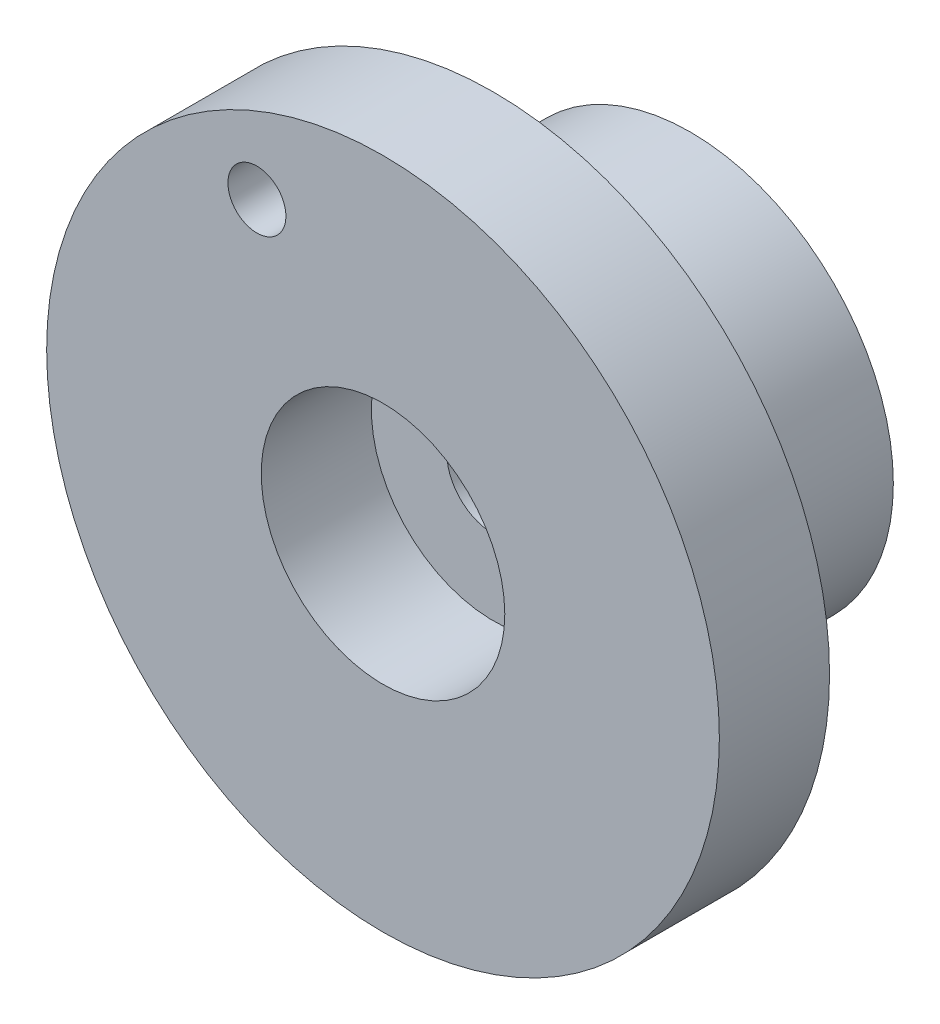
from build123d import *

# Parameters (mm, degrees)
SKETCH_1_R          = 29
SKETCH_1_R_2        = 10.5
EXTRUDE_1_DEPTH     = 9.5
SKETCH_2_R          = 17.5
SKETCH_2_R_2        = 4
EXTRUDE_2_DEPTH     = 17
SKETCH_3_R          = 2.5
CUT_EXTRUDE_1_DEPTH = 17


with BuildPart() as part:
    # Эскиз1 → Бобышка-Вытянуть1 (new body)
    with BuildSketch(Plane.XY):
        Circle(SKETCH_1_R)
        Circle(SKETCH_1_R_2, mode=Mode.SUBTRACT)
    extrude(amount=EXTRUDE_1_DEPTH)

    # Эскиз2 → Бобышка-Вытянуть2 (add)
    with BuildSketch(Plane(origin=(0, 0, 0), x_dir=(-1, 0, 0), z_dir=(0, 0, -1))):
        Circle(SKETCH_2_R)
        Circle(SKETCH_2_R_2, mode=Mode.SUBTRACT)
    extrude(amount=EXTRUDE_2_DEPTH)

    # Эскиз3 → Вырез-Вытянуть1 (cut)
    with BuildSketch(Plane.XY.offset(9.5)):
        with Locations((-10.871713138, 20.268346096)):
            Circle(SKETCH_3_R)
    extrude(amount=-CUT_EXTRUDE_1_DEPTH, mode=Mode.SUBTRACT)


solid = part.part
